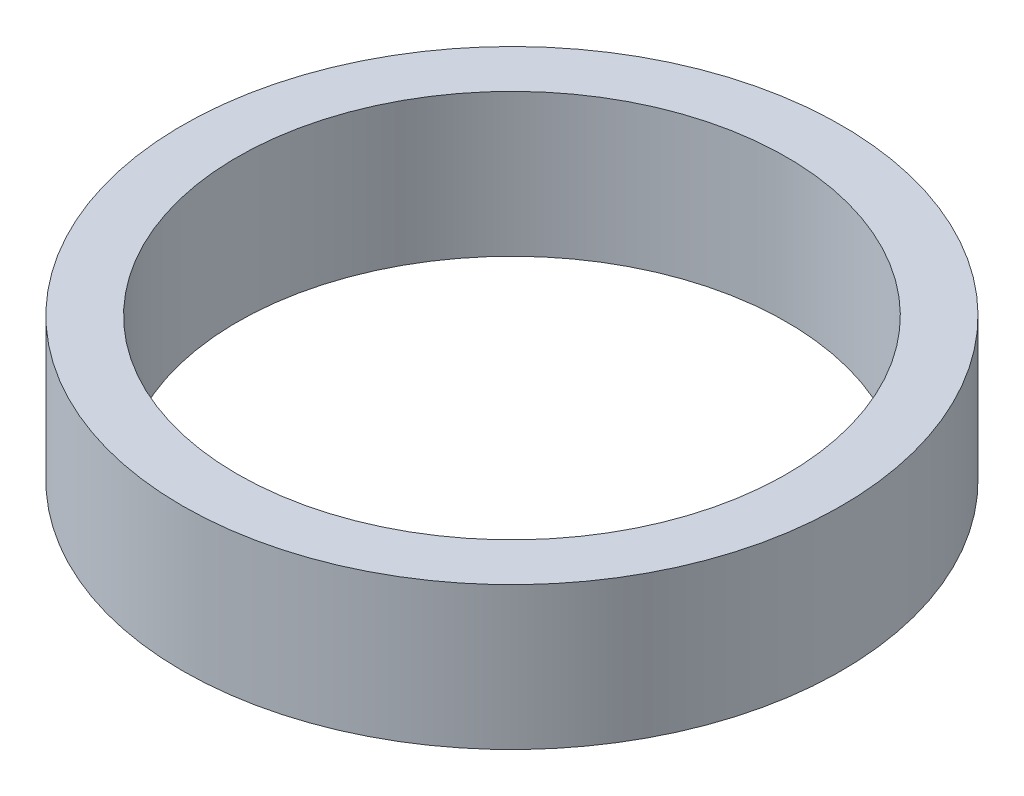
from build123d import *

# Parameters (mm, degrees)
SKETCH1_R           = 30
SKETCH1_R_2         = 25
BOSS_EXTRUDE1_DEPTH = 6.5


with BuildPart() as part:
    # Sketch1 → Boss-Extrude1 (new body, symmetric)
    with BuildSketch(Plane(origin=(0, 0, 0), x_dir=(1, 0, 0), z_dir=(0, 1, 0))):
        Circle(SKETCH1_R)
        Circle(SKETCH1_R_2, mode=Mode.SUBTRACT)
    extrude(amount=BOSS_EXTRUDE1_DEPTH, both=True)


solid = part.part
